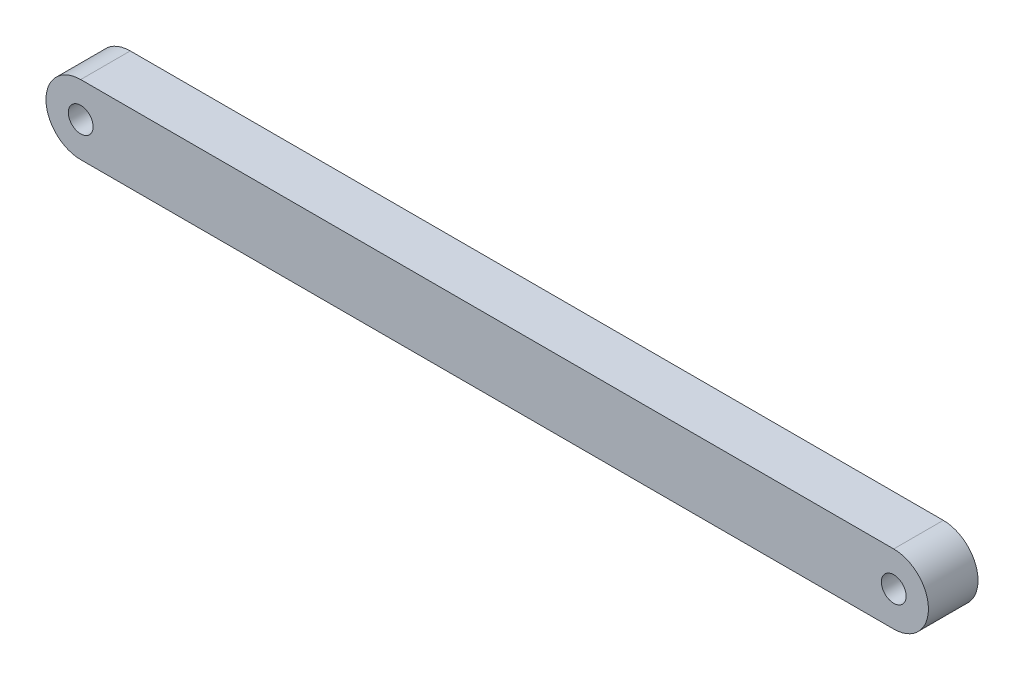
from build123d import *

# Parameters (mm, degrees)
SKETCH1_R           = 2.5
BOSS_EXTRUDE1_DEPTH = 5


with BuildPart() as part:
    # Sketch1 → Boss-Extrude1 (new body, symmetric)
    with BuildSketch(Plane.XY):
        with BuildLine():
            Line((0, 7), (164, 7))
            ThreePointArc((164, 7), (171, 0), (164, -7))
            Line((164, -7), (0, -7))
            ThreePointArc((0, -7), (-7, 0), (0, 7))
        make_face()
        Circle(SKETCH1_R, mode=Mode.SUBTRACT)
        with Locations((164, 0)):
            Circle(SKETCH1_R, mode=Mode.SUBTRACT)
    extrude(amount=BOSS_EXTRUDE1_DEPTH, both=True)


solid = part.part
